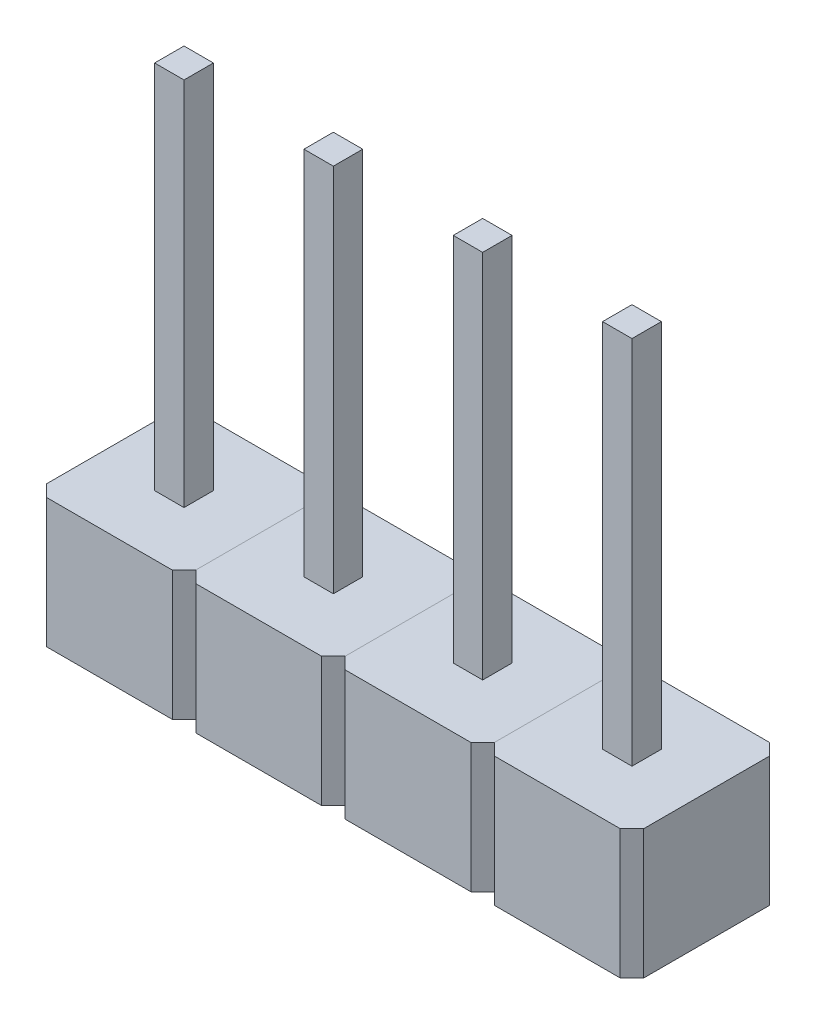
from build123d import *

# Parameters (mm, degrees)
CROQUIS1_W       = 0.5
CROQUIS1_H       = 0.5
EXTRUIR1_DEPTH   = 8.5
EXTRUIR1_2_DEPTH = 8.5
EXTRUIR1_3_DEPTH = 8.5
EXTRUIR1_4_DEPTH = 8.5
CROQUIS2_W       = 2.54
CROQUIS2_H       = 2.54
CROQUIS2_W_2     = 0.5
CROQUIS2_H_2     = 0.5
EXTRUIR2_DEPTH   = 2.2
CHAFL_N1_SIZE    = 0.2
MATRIZL1_COUNT   = 4
MATRIZL1_PITCH   = 2.54


with BuildPart() as part:
    # Croquis1 → Extruir1 (new body)
    with BuildSketch(Plane(origin=(0, 0, 0), x_dir=(1, 0, 0), z_dir=(0, 1, 0))):
        with Locations((2.79, 0.25)):
            Rectangle(CROQUIS1_W, CROQUIS1_H)
    extrude(amount=EXTRUIR1_DEPTH)


with BuildPart() as body_2:
    # Croquis1 → Extruir1 2 (new body)
    with BuildSketch(Plane(origin=(0, 0, 0), x_dir=(1, 0, 0), z_dir=(0, 1, 0))):
        with Locations((0.25, 0.25)):
            Rectangle(CROQUIS1_W, CROQUIS1_H)
    extrude(amount=EXTRUIR1_2_DEPTH)


with BuildPart() as body_3:
    # Croquis1 → Extruir1 3 (new body)
    with BuildSketch(Plane(origin=(0, 0, 0), x_dir=(1, 0, 0), z_dir=(0, 1, 0))):
        with Locations((5.33, 0.25)):
            Rectangle(CROQUIS1_W, CROQUIS1_H)
    extrude(amount=EXTRUIR1_3_DEPTH)


with BuildPart() as body_4:
    # Croquis1 → Extruir1 4 (new body)
    with BuildSketch(Plane(origin=(0, 0, 0), x_dir=(1, 0, 0), z_dir=(0, 1, 0))):
        with Locations((7.87, 0.25)):
            Rectangle(CROQUIS1_W, CROQUIS1_H)
    extrude(amount=EXTRUIR1_4_DEPTH)


with BuildPart() as body_5:
    # Croquis2 → Extruir2 (new body)
    with BuildSketch(Plane.XZ):
        with Locations((0.25, -0.25)):
            Rectangle(CROQUIS2_W, CROQUIS2_H)
        with Locations((0.25, -0.25)):
            Rectangle(CROQUIS2_W_2, CROQUIS2_H_2, mode=Mode.SUBTRACT)
    extrude(amount=-EXTRUIR2_DEPTH)

    # Chaflán1
    chafl_n1_edges = [body_5.edges().sort_by_distance(p)[0] for p in [
        (-1.02, 1.1, 1.02),
        (1.52, 1.1, 1.02),
        (1.52, 1.1, -1.52),
        (-1.02, 1.1, -1.52),
    ]]
    chamfer(chafl_n1_edges, length=CHAFL_N1_SIZE)


with BuildPart() as matrizl1_1:
    # MatrizL1: pattern copy
    add(body_5.part.moved(Location(Vector(1, 0, 0) * (1 * MATRIZL1_PITCH))))


with BuildPart() as matrizl1_2:
    # MatrizL1: pattern copy
    add(body_5.part.moved(Location(Vector(1, 0, 0) * (2 * MATRIZL1_PITCH))))


with BuildPart() as matrizl1_3:
    # MatrizL1: pattern copy
    add(body_5.part.moved(Location(Vector(1, 0, 0) * (3 * MATRIZL1_PITCH))))


solid = Compound([part.part, body_2.part, body_3.part, body_4.part, body_5.part, matrizl1_1.part, matrizl1_2.part, matrizl1_3.part])
